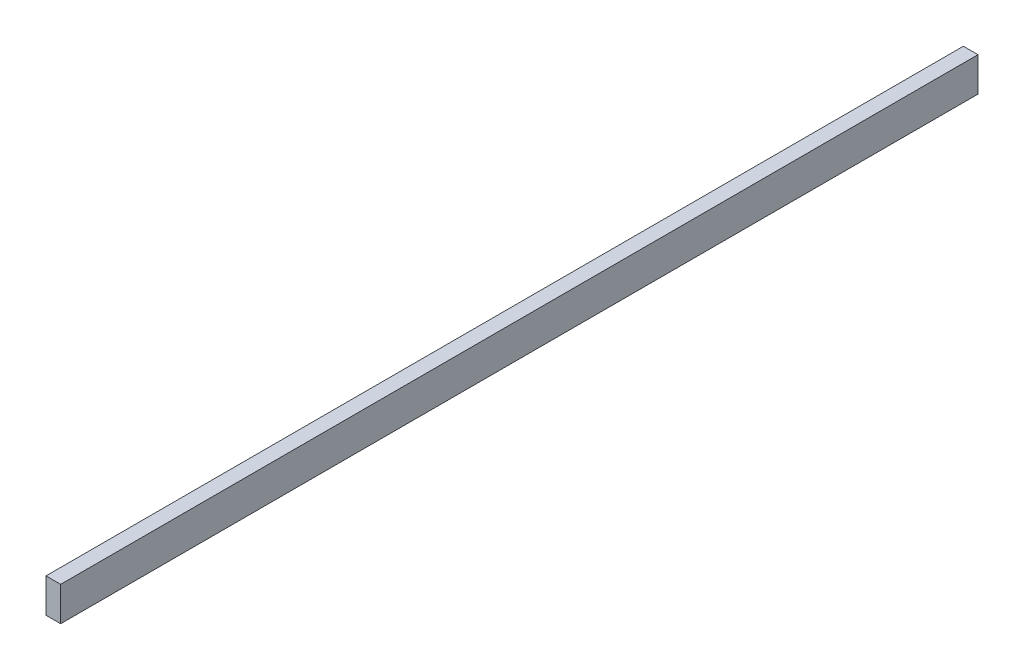
from build123d import *

# Parameters (mm, degrees)
SKETCH1_W           = 2387.6
SKETCH1_H           = 88.9
BOSS_EXTRUDE1_DEPTH = 38.1


with BuildPart() as part:
    # Sketch1 → Boss-Extrude1 (new body)
    with BuildSketch(Plane(origin=(0, 0, 0), x_dir=(0, 0, -1), z_dir=(1, 0, 0))):
        Rectangle(SKETCH1_W, SKETCH1_H)
    extrude(amount=BOSS_EXTRUDE1_DEPTH)


solid = part.part
